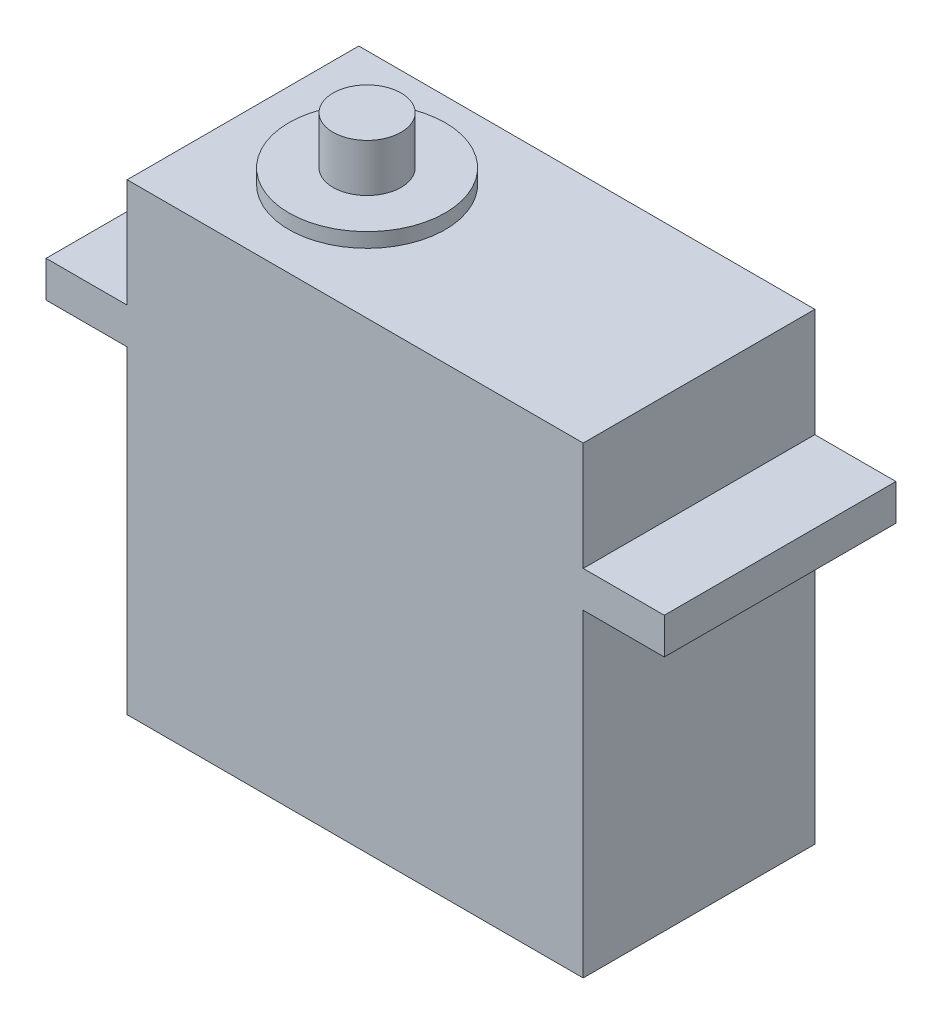
from build123d import *

# Parameters (mm, degrees)
BOSS_EXTRUDE1_DEPTH = 20.32
SKETCH2_R           = 6.858
BOSS_EXTRUDE2_DEPTH = 1.27
SKETCH3_R           = 2.9845
BOSS_EXTRUDE3_DEPTH = 4.191


with BuildPart() as part:
    # Sketch1 → Boss-Extrude1 (new body)
    with BuildSketch(Plane.XY):
        Polygon((0, 0), (40.005, 0), (40.005, 27.94), (47.117, 27.94), (47.117, 31.115), (40.005, 31.115), (40.005, 40.64), (0, 40.64), (0, 31.115), (-7.112, 31.115), (-7.112, 27.94), (0, 27.94), align=None)
    extrude(amount=BOSS_EXTRUDE1_DEPTH)

    # Sketch2 → Boss-Extrude2 (add)
    with BuildSketch(Plane(origin=(0, 40.64, 0), x_dir=(1, 0, 0), z_dir=(0, 1, 0))):
        with Locations((10.886333584, -10.16)):
            Circle(SKETCH2_R)
    extrude(amount=BOSS_EXTRUDE2_DEPTH)

    # Sketch3 → Boss-Extrude3 (add)
    with BuildSketch(Plane(origin=(0, 41.91, 0), x_dir=(1, 0, 0), z_dir=(0, 1, 0))):
        with Locations((10.886333584, -10.16)):
            Circle(SKETCH3_R)
    extrude(amount=BOSS_EXTRUDE3_DEPTH)


solid = part.part
